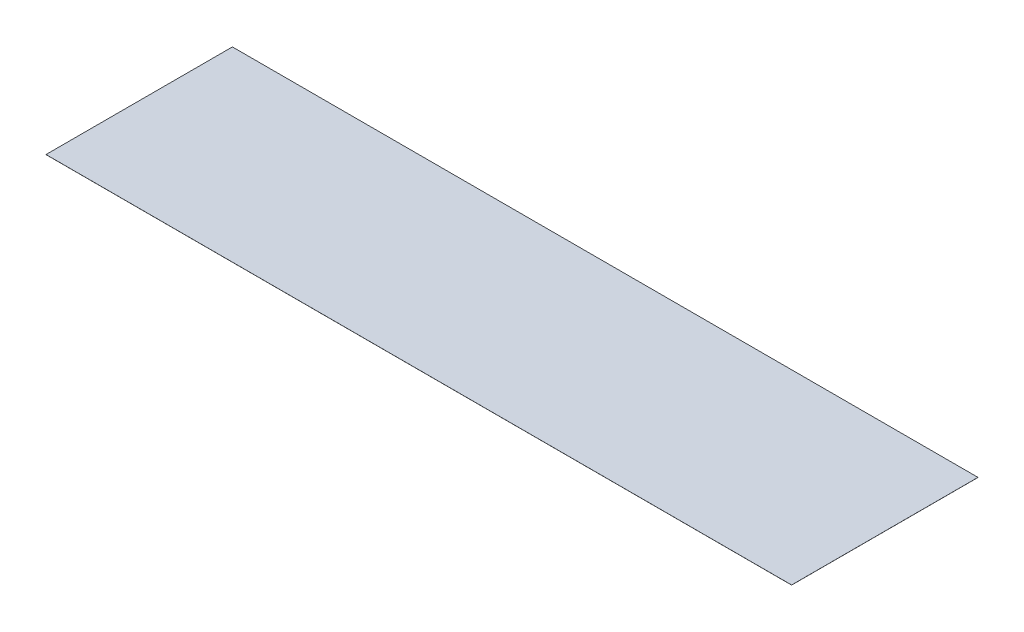
from build123d import *

# Parameters (mm, degrees)
SKETCH1_W           = 8000
SKETCH1_H           = 2000
BOSS_EXTRUDE1_DEPTH = 1


with BuildPart() as part:
    # Sketch1 → Boss-Extrude1 (new body)
    with BuildSketch(Plane(origin=(0, 0, 0), x_dir=(1, 0, 0), z_dir=(0, 1, 0))):
        Rectangle(SKETCH1_W, SKETCH1_H)
    extrude(amount=BOSS_EXTRUDE1_DEPTH)


solid = part.part
